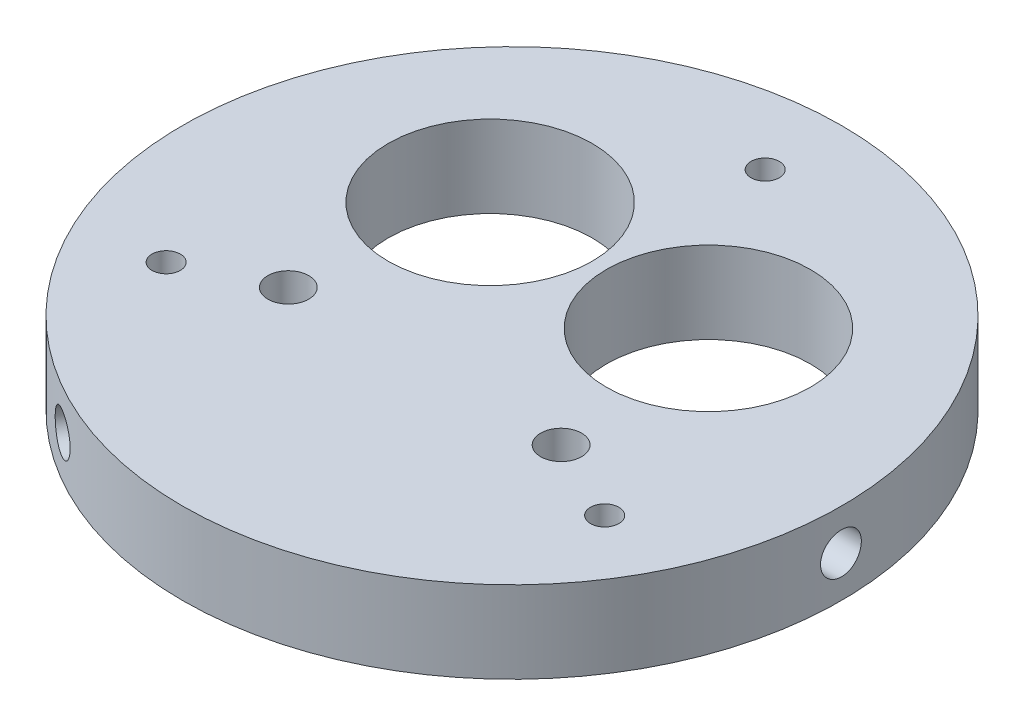
from build123d import *

# Parameters (mm, degrees)
SKETCH1_R               = 38.354
BOSS_EXTRUDE1_DEPTH     = 9.525
SKETCH2_R               = 1.651
SKETCH2_R_2             = 11.8745
CUT_EXTRUDE1_DEPTH      = 56.070720506
SKETCH4_R               = 2.3749
CUT_EXTRUDE2_DEPTH      = 6.35
CIRPATTERN1_COUNT       = 3
CUT_EXTRUDE3_DEPTH      = 56.070720662
CUT_EXTRUDE3_DEPTH_BACK = 56.070720662
SKETCH5_R               = 2.38125


with BuildPart() as part:
    # Sketch1 → Boss-Extrude1 (new body)
    with BuildSketch(Plane(origin=(0, 0, 0), x_dir=(1, 0, 0), z_dir=(0, 1, 0))):
        Circle(SKETCH1_R)
    extrude(amount=BOSS_EXTRUDE1_DEPTH)

    # Sketch2 → Cut-Extrude1 (cut, through all)
    with BuildSketch(Plane(origin=(0, 9.525, 0), x_dir=(1, 0, 0), z_dir=(0, 1, 0))):
        with Locations((0, 29.464)):
            Circle(SKETCH2_R)
        with Locations((25.516572497, -14.732)):
            Circle(SKETCH2_R)
        with Locations((-25.516572497, -14.732)):
            Circle(SKETCH2_R)
        with Locations((-12.7, 10.16)):
            Circle(SKETCH2_R_2)
        with Locations((12.7, 10.16)):
            Circle(SKETCH2_R_2)
    extrude(amount=-CUT_EXTRUDE1_DEPTH, mode=Mode.SUBTRACT)

    # Sketch4 → Cut-Extrude2 (cut)
    with BuildSketch(Plane(origin=(-19.177, 0, -33.215538337), x_dir=(0, -1, 0), z_dir=(-0.499999999999998, 0, -0.8660254037844398))):
        with Locations((-4.7625, 0)):
            Circle(SKETCH4_R)
    cut_extrude2 = extrude(amount=-CUT_EXTRUDE2_DEPTH, mode=Mode.SUBTRACT)

    # CirPattern1: Cut-Extrude2 ×3 about axis
    cirpattern1_axis = Axis((0, 10.00125, 0), (0, -1, 0))
    for i in range(1, CIRPATTERN1_COUNT):
        add(cut_extrude2.rotate(cirpattern1_axis, i * 360 / CIRPATTERN1_COUNT), mode=Mode.SUBTRACT)

    # Sketch5 → Cut-Extrude3 (cut, two sides: drawn at the far end of the back side and taken through both)
    with BuildSketch(Plane(origin=(0, 9.525, 0), x_dir=(1, 0, 0), z_dir=(0, 1, 0)).offset(-CUT_EXTRUDE3_DEPTH_BACK)):
        with Locations((-15.875, -10.16)):
            Circle(SKETCH5_R)
        with Locations((15.875, -10.16)):
            Circle(SKETCH5_R)
    extrude(amount=CUT_EXTRUDE3_DEPTH + CUT_EXTRUDE3_DEPTH_BACK, mode=Mode.SUBTRACT)


solid = part.part
